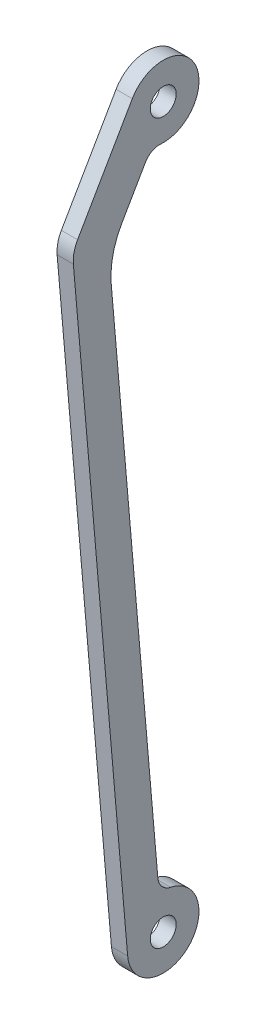
from build123d import *

# Parameters (mm, degrees)
SKETCH1_R             = 4
SKETCH1_R_2           = 3.999999999
BOSS_EXTRUDE1_DEPTH   = 5
BODY_MOVE_COPY1_ANGLE = 90


with BuildPart() as part:
    # Sketch1 → Boss-Extrude1 (new body)
    with BuildSketch(Plane(origin=(0, 0, 0), x_dir=(1, 0, 0), z_dir=(0, 1, 0))):
        with BuildLine():
            Line((-5.5, -9.526279442), (23.673254908, -26.369466016))
            ThreePointArc((23.673254908, -26.369466016), (26.504938869, -27.471302202), (29.53681211, -27.671855651))
            Line((29.53681211, -27.671855651), (222.349912922, -10.958908038))
            ThreePointArc((222.349912922, -10.958908038), (229.638892539, 7.288391438), (210.63878065, 2.279508305))
            ThreePointArc((210.63878065, 2.279508305), (209.060222507, -0.429302712), (206.17909591, -1.665673394))
            Line((206.17909591, -1.665673394), (40.742030274, -16.005679335))
            ThreePointArc((40.742030274, -16.005679335), (33.162347172, -15.504295714), (26.08313727, -12.749705247))
            Line((26.08313727, -12.749705247), (13.459935794, -5.461696477))
            ThreePointArc((13.459935794, -5.461696477), (11.544061041, -3.476788033), (10.972455859, -0.777954003))
            ThreePointArc((10.972455859, -0.777954003), (-5.159480863, 9.714924458), (-5.5, -9.526279442))
        make_face()
        Circle(SKETCH1_R, mode=Mode.SUBTRACT)
        with Locations((221.4, 2e-09)):
            Circle(SKETCH1_R_2, mode=Mode.SUBTRACT)
    extrude(amount=BOSS_EXTRUDE1_DEPTH)


with BuildPart() as part_1:
    # Body-Move/Copy1: moved
    add(part.part.rotate(Axis((110.7, 2.5, 0), (0, 0, -1)), BODY_MOVE_COPY1_ANGLE))


solid = part_1.part
